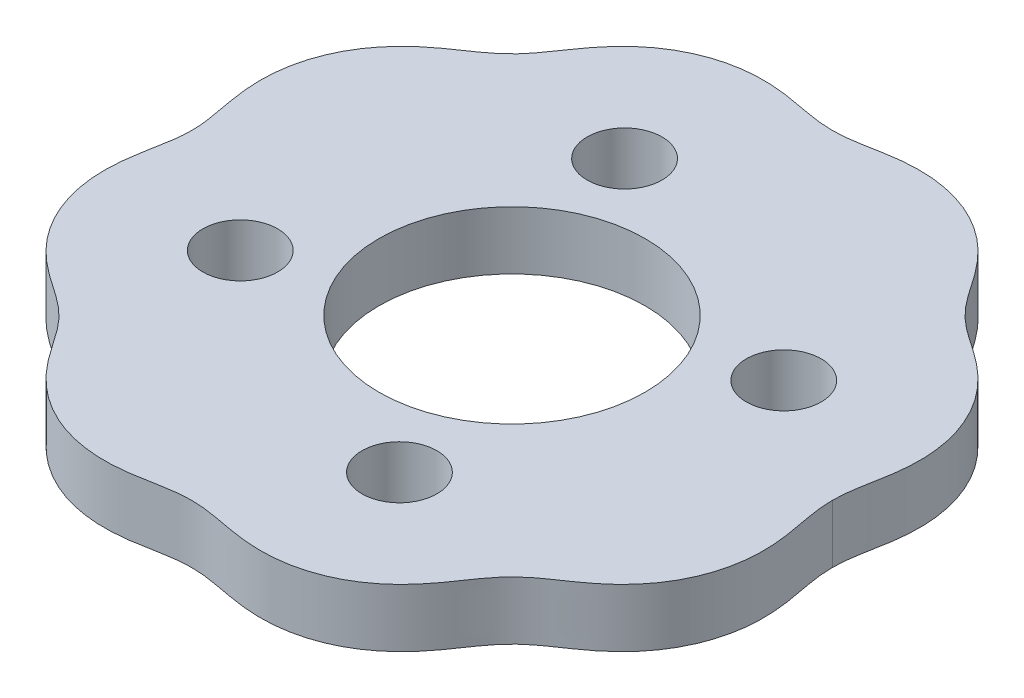
from build123d import *

# Parameters (mm, degrees)
BOSS_EXTRUDE1_DEPTH = 7
SKETCH3_R           = 4.5
SKETCH3_R_2         = 16
CUT_EXTRUDE1_DEPTH  = 7


with BuildPart() as part:
    # Sketch2 → Boss-Extrude1 (new body)
    with BuildSketch(Plane(origin=(0, 0, 0), x_dir=(1, 0, 0), z_dir=(0, 1, 0))):
        with BuildLine():
            add(Edge.make_bspline(
                [(38.500001932, 0), (38.49999493, -0.133038025), (38.504303168, -0.465241084), (38.528527213, -0.995915147), (38.597299004, -1.723581558), (38.713954373, -2.556473402), (38.865640285, -3.429000232), (39.039182268, -4.342476136), (39.216569329, -5.300601097), (39.373506849, -6.262329219), (39.498072372, -7.228937475), (39.602679415, -8.442781449), (39.638401085, -10.080498863), (39.471343171, -12.134870391), (38.917723366, -14.556663115), (37.916874201, -17.021348245), (36.631880328, -19.132177598), (35.181255459, -20.890168269), (33.668641012, -22.329615502), (32.17746468, -23.504918274), (30.676775717, -24.53637227), (29.230318997, -25.511931365), (27.908200853, -26.534151326), (26.76343469, -27.648078887), (25.705045065, -28.957902171), (24.707260932, -30.418954005), (23.665711077, -31.956210315), (22.477076324, -33.498381096), (21.029299745, -35.052946841), (19.26697752, -36.536660954), (17.157957829, -37.84717065), (14.702426065, -38.871299083), (11.814083944, -39.558976123), (9.019891244, -39.705335471), (6.423310178, -39.43632976), (4.13591504, -38.999279115), (2.419501708, -38.673186875), (0.778249626, -38.485160743), (-0.77822635, -38.485379818), (-2.419580838, -38.672889794), (-4.135742829, -38.999747405), (-5.946996654, -39.344647228), (-7.875168754, -39.5873623), (-9.995420298, -39.653717755), (-12.288096474, -39.44656229), (-15.348952193, -38.716751342), (-18.204257408, -37.344912694), (-20.577802729, -35.538571367), (-22.476801363, -33.498259602), (-23.6659125, -31.956297347), (-24.707137732, -30.418901145), (-25.705109441, -28.957929727), (-26.76339803, -27.648063208), (-27.908223694, -26.534161088), (-29.230302417, -25.511924287), (-30.67678613, -24.536376699), (-32.177458812, -23.504915804), (-33.668643628, -22.329616565), (-35.181253946, -20.890167706), (-36.631881301, -19.132177878), (-37.916873533, -17.021348182), (-38.917723873, -14.556662976), (-39.471342711, -12.134870792), (-39.638401547, -10.080498118), (-39.602678844, -8.442782724), (-39.498073444, -7.228934716), (-39.389075524, -6.383160667), (-39.275422946, -5.661243945), (-39.170944219, -5.061294369), (-39.083249028, -4.582074459), (-38.99344233, -4.103256554), (-38.90380396, -3.624381742), (-38.803034266, -3.068984042), (-38.697069036, -2.435815687), (-38.597293422, -1.72360163), (-38.528529639, -0.995905984), (-38.504303204, -0.465240188), (-38.499994567, -0.133038295), (-38.500001565, 0)],
                knots=[0.102276964, 0.102276964, 0.102276964, 0.102276964, 0.102276964, 0.105556816, 0.110467405, 0.115377995, 0.120288584, 0.126295597, 0.13230261, 0.138309622, 0.144316635, 0.150323647, 0.15633066, 0.168344685, 0.184673889, 0.201003094, 0.217332381, 0.233661668, 0.245353827, 0.257045987, 0.268738146, 0.280430306, 0.290251572, 0.300072838, 0.309894104, 0.31971537, 0.331705497, 0.343695624, 0.355685751, 0.367675878, 0.384005122, 0.400334365, 0.416663644, 0.432992923, 0.456925422, 0.468891671, 0.48085792, 0.49042896, 0.5, 0.50957104, 0.51914208, 0.531108329, 0.543074578, 0.555040828, 0.567007077, 0.583336356, 0.599665635, 0.632324122, 0.644314249, 0.656304376, 0.668294503, 0.68028463, 0.690105896, 0.699927162, 0.709748428, 0.719569694, 0.731261854, 0.742954013, 0.754646173, 0.766338332, 0.782667619, 0.798996906, 0.815326111, 0.831655315, 0.84366934, 0.849676353, 0.855683365, 0.861690378, 0.864693884, 0.86769739, 0.870700897, 0.873704403, 0.876707909, 0.879711416, 0.884622005, 0.889532595, 0.894443184, 0.897723044, 0.897723044, 0.897723044, 0.897723044, 0.897723044], degree=4))
            add(Edge.make_bspline(
                [(38.500001932, 0), (38.49999493, 0.133038025), (38.504303168, 0.465241084), (38.528527213, 0.995915147), (38.597299004, 1.723581558), (38.713954373, 2.556473402), (38.865640285, 3.429000232), (39.039182268, 4.342476136), (39.216569329, 5.300601097), (39.373506849, 6.262329219), (39.498072372, 7.228937475), (39.602679415, 8.442781449), (39.638401085, 10.080498864), (39.471343171, 12.134870391), (38.917723366, 14.556663115), (37.916874201, 17.021348245), (36.631880327, 19.132177598), (35.181255459, 20.890168269), (33.668641012, 22.329615503), (32.177464679, 23.504918274), (30.676775717, 24.53637227), (29.230318997, 25.511931365), (27.908200853, 26.534151326), (26.76343469, 27.648078887), (25.705045065, 28.957902171), (24.707260932, 30.418954006), (23.665711077, 31.956210316), (22.477076324, 33.498381097), (21.029299745, 35.052946841), (19.26697752, 36.536660954), (17.157957829, 37.84717065), (14.702426064, 38.871299083), (11.814083944, 39.558976123), (9.019891244, 39.705335471), (6.423310178, 39.436329761), (4.13591504, 38.999279115), (2.419501708, 38.673186876), (0.778249626, 38.485160743), (-0.77822635, 38.485379818), (-2.419580838, 38.672889794), (-4.13574283, 38.999747405), (-5.946996654, 39.344647228), (-7.875168754, 39.5873623), (-9.995420299, 39.653717755), (-12.288096474, 39.446562291), (-15.348952193, 38.716751342), (-18.204257408, 37.344912694), (-20.577802729, 35.538571367), (-22.476801363, 33.498259602), (-23.6659125, 31.956297347), (-24.707137732, 30.418901145), (-25.705109441, 28.957929727), (-26.763398031, 27.648063208), (-27.908223694, 26.534161088), (-29.230302417, 25.511924287), (-30.67678613, 24.536376699), (-32.177458812, 23.504915804), (-33.668643628, 22.329616565), (-35.181253946, 20.890167706), (-36.631881301, 19.132177878), (-37.916873533, 17.021348182), (-38.917723873, 14.556662976), (-39.471342711, 12.134870792), (-39.638401547, 10.080498118), (-39.602678844, 8.442782724), (-39.498073444, 7.228934716), (-39.389075524, 6.383160667), (-39.275422946, 5.661243945), (-39.170944219, 5.061294369), (-39.083249028, 4.582074459), (-38.99344233, 4.103256554), (-38.90380396, 3.624381743), (-38.803034266, 3.068984042), (-38.697069036, 2.435815687), (-38.597293422, 1.72360163), (-38.528529639, 0.995905984), (-38.504303204, 0.465240188), (-38.499994567, 0.133038294), (-38.500001565, 0)],
                knots=[0.102276964, 0.102276964, 0.102276964, 0.102276964, 0.102276964, 0.105556816, 0.110467405, 0.115377995, 0.120288584, 0.126295597, 0.13230261, 0.138309622, 0.144316635, 0.150323647, 0.15633066, 0.168344685, 0.184673889, 0.201003094, 0.217332381, 0.233661668, 0.245353827, 0.257045987, 0.268738146, 0.280430306, 0.290251572, 0.300072838, 0.309894104, 0.31971537, 0.331705497, 0.343695624, 0.355685751, 0.367675878, 0.384005122, 0.400334365, 0.416663644, 0.432992923, 0.456925422, 0.468891671, 0.48085792, 0.49042896, 0.5, 0.50957104, 0.51914208, 0.531108329, 0.543074578, 0.555040828, 0.567007077, 0.583336356, 0.599665635, 0.632324122, 0.644314249, 0.656304376, 0.668294503, 0.68028463, 0.690105896, 0.699927162, 0.709748428, 0.719569694, 0.731261854, 0.742954013, 0.754646173, 0.766338332, 0.782667619, 0.798996906, 0.815326111, 0.831655315, 0.84366934, 0.849676353, 0.855683365, 0.861690378, 0.864693884, 0.86769739, 0.870700897, 0.873704403, 0.876707909, 0.879711416, 0.884622005, 0.889532595, 0.894443184, 0.897723044, 0.897723044, 0.897723044, 0.897723044, 0.897723044], degree=4))
        make_face()
    extrude(amount=BOSS_EXTRUDE1_DEPTH)

    # Sketch3 → Cut-Extrude1 (cut)
    with BuildSketch(Plane(origin=(0, 7, 0), x_dir=(1, 0, 0), z_dir=(0, 1, 0))):
        with Locations(Location((23.096995347, 9.567068827, 0), (0, 0, 270))):
            Circle(SKETCH3_R)
        with Locations(Location((9.567068827, -23.096995347, 0), (0, 0, 270))):
            Circle(SKETCH3_R)
        with Locations(Location((-23.096995347, -9.567068827, 0), (0, 0, 270))):
            Circle(SKETCH3_R)
        with Locations(Location((-9.567068827, 23.096995347, 0), (0, 0, 270))):
            Circle(SKETCH3_R)
        with Locations(Location((0, 0, 0), (0, 0, 270))):
            Circle(SKETCH3_R_2)
    extrude(amount=-CUT_EXTRUDE1_DEPTH, mode=Mode.SUBTRACT)


solid = part.part
